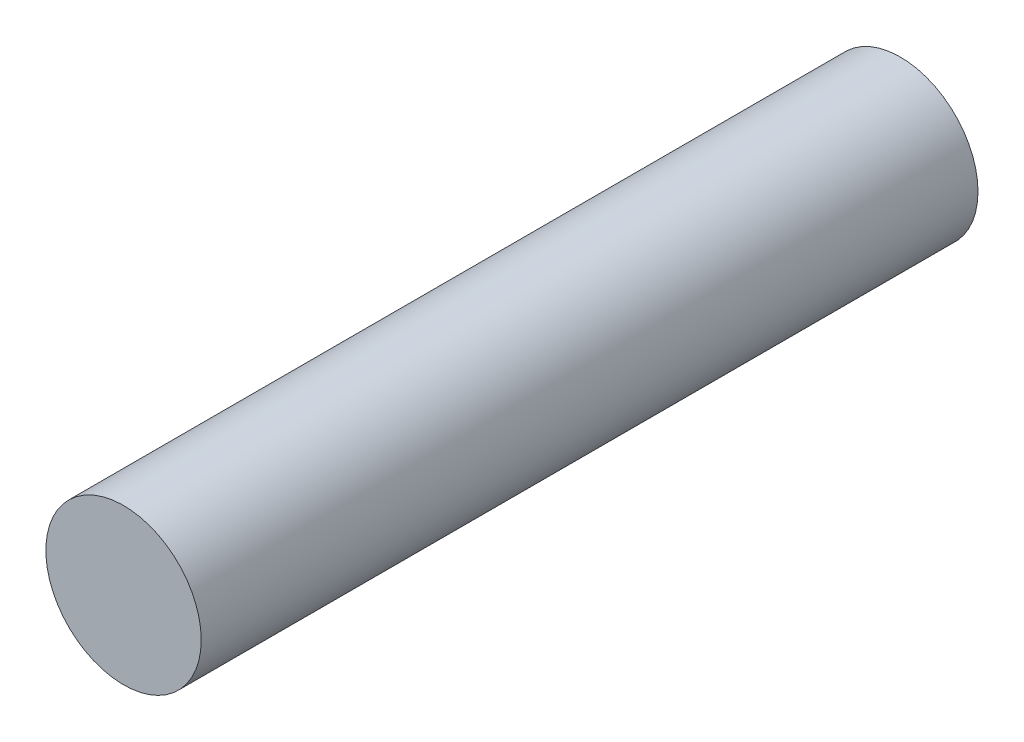
from build123d import *

# Parameters (mm, degrees)
SKETCH1_R           = 3.5
BOSS_EXTRUDE1_DEPTH = 35


with BuildPart() as part:
    # Sketch1 → Boss-Extrude1 (new body)
    with BuildSketch(Plane.XY):
        with Locations((-16.029550071, 18.92278798)):
            Circle(SKETCH1_R)
    extrude(amount=BOSS_EXTRUDE1_DEPTH)


solid = part.part
